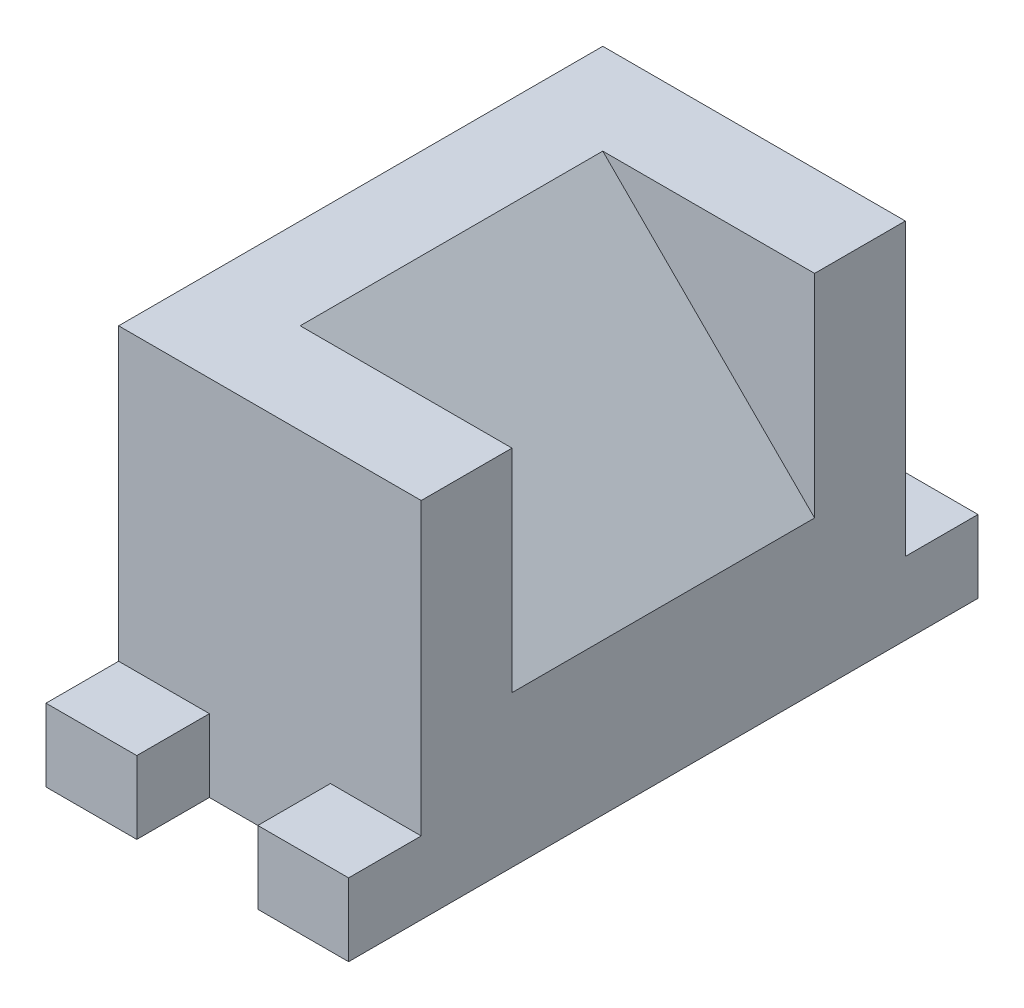
from build123d import *

# Parameters (mm, degrees)
IZIM1_W                     = 50
IZIM1_H                     = 80
Y_KSEKLIK_EKSTR_ZYON2_DEPTH = 60
IZIM2_W                     = 15
IZIM2_H                     = 12
Y_KSEKLIK_EKSTR_ZYON3_DEPTH = 12
AYNALAMA2_COPY_1_SKETCH_W   = 15
AYNALAMA2_COPY_1_SKETCH_H   = 12
AYNALAMA2_COPY_1_DEPTH      = 12
KES_EKSTR_ZYON1_DEPTH       = 50


with BuildPart() as part:
    # Çizim1 → Yükseklik-Ekstrüzyon2 (new body)
    with BuildSketch(Plane(origin=(0, 0, 0), x_dir=(1, 0, 0), z_dir=(0, 1, 0))):
        Rectangle(IZIM1_W, IZIM1_H)
    extrude(amount=Y_KSEKLIK_EKSTR_ZYON2_DEPTH)

    # Çizim2 → Yükseklik-Ekstrüzyon3 (add)
    with BuildSketch(Plane.XY.offset(40)):
        with Locations((-17.5, 6)):
            Rectangle(IZIM2_W, IZIM2_H)
    y_kseklik_ekstr_zyon3 = extrude(amount=Y_KSEKLIK_EKSTR_ZYON3_DEPTH)

    # Aynalama1: Yükseklik-Ekstrüzyon3 across plane
    add(y_kseklik_ekstr_zyon3.mirror(Plane(origin=(0, 0, 0), x_dir=(0, 0, 1), z_dir=(1, 0, 0))))

    # Aynalama2: Yükseklik-Ekstrüzyon3 across plane
    add(y_kseklik_ekstr_zyon3.mirror(Plane.XY))

    # Aynalama2 copy 1 sketch → Aynalama2 copy 1 (add)
    with BuildSketch(Plane(origin=(0, 0, -40), x_dir=(-1, 0, 0), z_dir=(0, 0, -1))):
        with Locations((-17.5, 6)):
            Rectangle(AYNALAMA2_COPY_1_SKETCH_W, AYNALAMA2_COPY_1_SKETCH_H)
    extrude(amount=AYNALAMA2_COPY_1_DEPTH)

    # Çizim3 → Kes-Ekstrüzyon1 (cut)
    with BuildSketch(Plane.XY.offset(25)):
        Polygon((-10, 60), (25, 25), (25, 60), align=None)
    extrude(amount=-KES_EKSTR_ZYON1_DEPTH, mode=Mode.SUBTRACT)


solid = part.part
